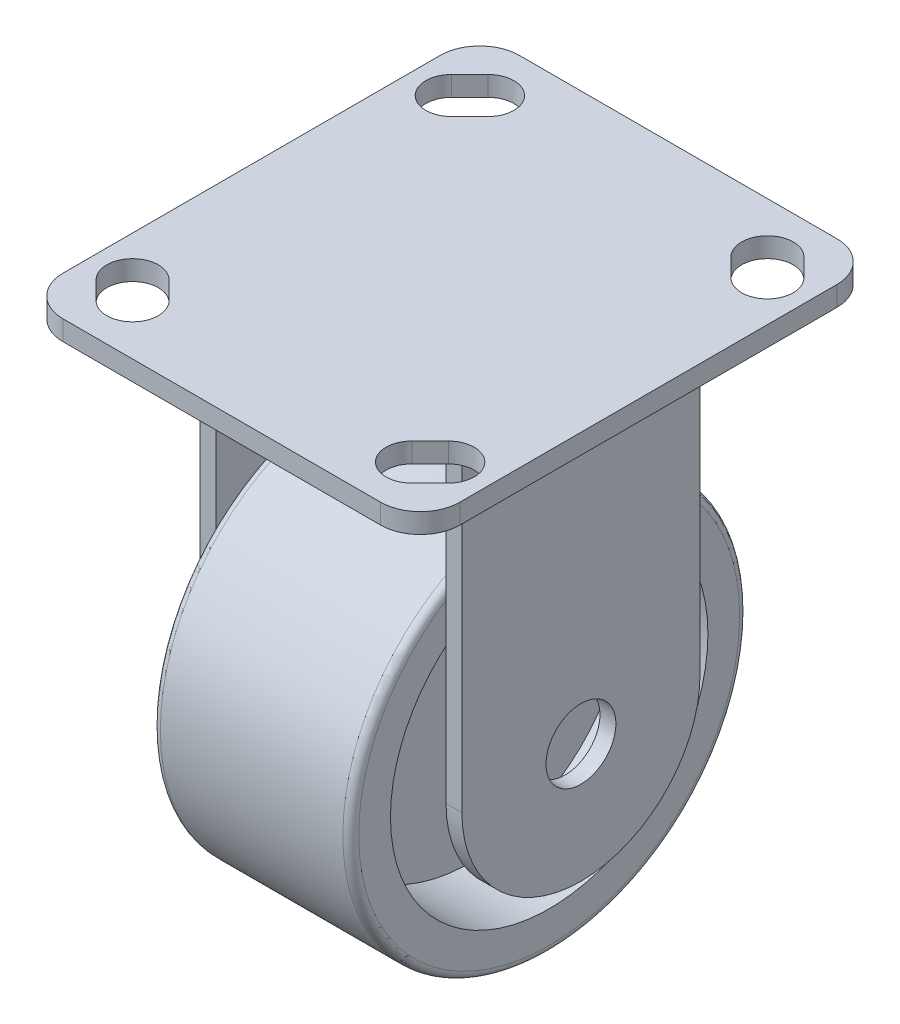
from build123d import *

# Parameters (mm, degrees)
SKETCH1_R           = 50
SKETCH1_R_2         = 5
BOSS_EXTRUDE1_DEPTH = 25
CUT_EXTRUDE1_START  = -5
SKETCH3_R           = 40
CUT_EXTRUDE1_DEPTH  = 20
CUT_EXTRUDE2_START  = 25
SKETCH3_2_R         = 40
CUT_EXTRUDE2_DEPTH  = 20
SKETCH4_R           = 8.804244638
BOSS_EXTRUDE2_DEPTH = 4
SKETCH5_W           = 100
SKETCH5_H           = 115
BOSS_EXTRUDE3_DEPTH = 5
FILLET1_R           = 10
FILLET2_R           = 2


with BuildPart() as part:
    # Sketch1 → Boss-Extrude1 (new, symmetric)
    with BuildSketch(Plane(origin=(0, 0, 0), x_dir=(0, 0, -1), z_dir=(1, 0, 0))):
        Circle(SKETCH1_R)
        Circle(SKETCH1_R_2, mode=Mode.SUBTRACT)
    extrude(amount=BOSS_EXTRUDE1_DEPTH, both=True)

    # Sketch3 → Cut-Extrude1 (cut)
    with BuildSketch(Plane(origin=(0, 0, 0), x_dir=(0, 0, -1), z_dir=(1, 0, 0)).offset(CUT_EXTRUDE1_START)):
        Circle(SKETCH3_R)
    extrude(amount=-CUT_EXTRUDE1_DEPTH, mode=Mode.SUBTRACT)

    # Sketch3_2 → Cut-Extrude2 (cut)
    with BuildSketch(Plane(origin=(0, 0, 0), x_dir=(0, 0, -1), z_dir=(1, 0, 0)).offset(CUT_EXTRUDE2_START)):
        Circle(SKETCH3_2_R)
    extrude(amount=-CUT_EXTRUDE2_DEPTH, mode=Mode.SUBTRACT)

    # Fillet2
    fillet2_edges = [part.edges().sort_by_distance(p)[0] for p in [
        (-25, 0, 50),
        (25, 0, 50),
    ]]
    fillet(fillet2_edges, radius=FILLET2_R)


with BuildPart() as body_2:
    # Sketch4 → Boss-Extrude2 (new body)
    with BuildSketch(Plane.ZY.offset(29)):
        with BuildLine():
            Line((-30, 0), (-30, 80))
            Line((-30, 80), (30, 80))
            Line((30, 80), (30, 0))
            ThreePointArc((30, 0), (0, -30), (-30, 0))
        make_face()
        Circle(SKETCH4_R, mode=Mode.SUBTRACT)
    extrude(amount=BOSS_EXTRUDE2_DEPTH)


with BuildPart() as body_3:
    # Mirror4: mirrored copy
    add(body_2.part.mirror(Plane(origin=(0, 0, 0), x_dir=(0, 0, 1), z_dir=(1, 0, 0))))


with BuildPart() as body_2_1:
    add(body_2.part)

    add(body_3.part)  # Boss-Extrude3 merges body 3
    # Sketch5 → Boss-Extrude3 (add)
    with BuildSketch(Plane(origin=(0, 80, 0), x_dir=(1, 0, 0), z_dir=(0, 1, 0))):
        Rectangle(SKETCH5_W, SKETCH5_H)
        with BuildLine():
            Line((39.798097039, 49.394291117), (44.394291117, 44.798097039))
            ThreePointArc((44.394291117, 44.798097039), (44.394291117, 35.605708883), (35.201902961, 35.605708883))
            Line((35.201902961, 35.605708883), (30.605708883, 40.201902961))
            ThreePointArc((30.605708883, 40.201902961), (30.605708883, 49.394291117), (39.798097039, 49.394291117))
        make_face(mode=Mode.SUBTRACT)
        with BuildLine():
            Line((-44.394291117, 44.798097039), (-39.798097039, 49.394291117))
            ThreePointArc((-39.798097039, 49.394291117), (-30.605708883, 49.394291117), (-30.605708883, 40.201902961))
            Line((-30.605708883, 40.201902961), (-35.201902961, 35.605708883))
            ThreePointArc((-35.201902961, 35.605708883), (-44.394291117, 35.605708883), (-44.394291117, 44.798097039))
        make_face(mode=Mode.SUBTRACT)
        with BuildLine():
            Line((-35.201902961, -35.605708883), (-30.605708883, -40.201902961))
            ThreePointArc((-30.605708883, -40.201902961), (-30.605708883, -49.394291117), (-39.798097039, -49.394291117))
            Line((-39.798097039, -49.394291117), (-44.394291117, -44.798097039))
            ThreePointArc((-44.394291117, -44.798097039), (-44.394291117, -35.605708883), (-35.201902961, -35.605708883))
        make_face(mode=Mode.SUBTRACT)
        with BuildLine():
            Line((44.394291117, -44.798097039), (39.798097039, -49.394291117))
            ThreePointArc((39.798097039, -49.394291117), (30.605708883, -49.394291117), (30.605708883, -40.201902961))
            Line((30.605708883, -40.201902961), (35.201902961, -35.605708883))
            ThreePointArc((35.201902961, -35.605708883), (44.394291117, -35.605708883), (44.394291117, -44.798097039))
        make_face(mode=Mode.SUBTRACT)
    extrude(amount=BOSS_EXTRUDE3_DEPTH)

    # Fillet1
    fillet1_edges = [body_2_1.edges().sort_by_distance(p)[0] for p in [
        (50, 82.5, -57.5),
        (-50, 82.5, -57.5),
        (50, 82.5, 57.5),
        (-50, 82.5, 57.5),
    ]]
    fillet(fillet1_edges, radius=FILLET1_R)


solid = Compound([part.part, body_2_1.part])
